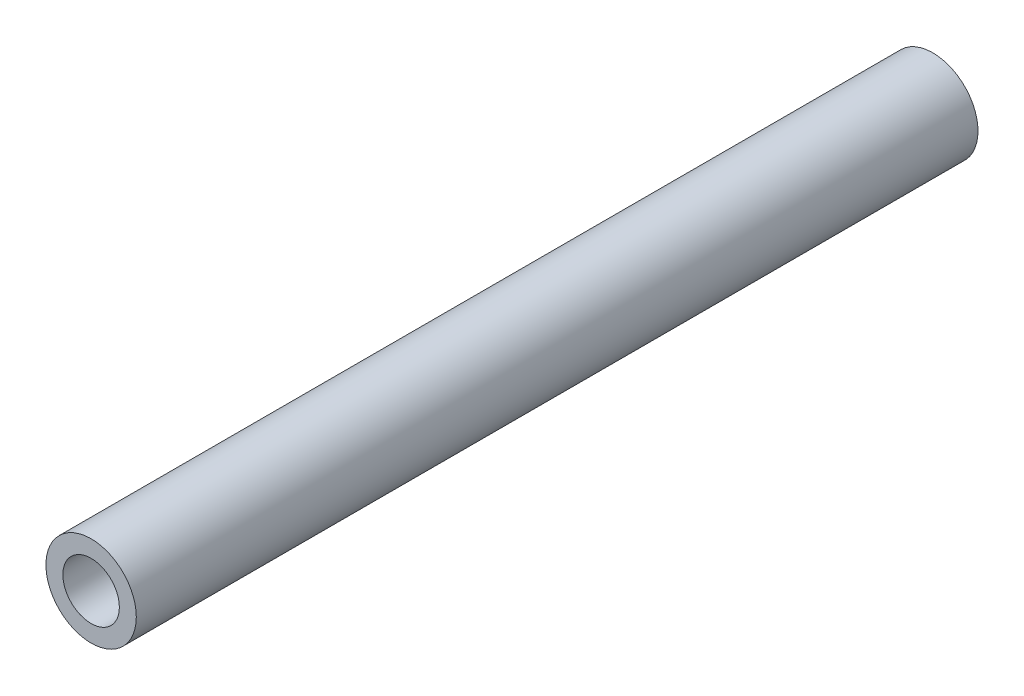
from build123d import *

# Parameters (mm, degrees)
SKETCH1_R           = 4
BOSS_EXTRUDE1_DEPTH = 74.5
SKETCH2_R           = 2.5
CUT_EXTRUDE1_DEPTH  = 16


with BuildPart() as part:
    # Sketch1 → Boss-Extrude1 (new body)
    with BuildSketch(Plane.XY):
        Circle(SKETCH1_R)
    extrude(amount=BOSS_EXTRUDE1_DEPTH)

    # Sketch2 → Cut-Extrude1 (cut)
    with BuildSketch(Plane.XY.offset(74.5)):
        Circle(SKETCH2_R)
    extrude(amount=-CUT_EXTRUDE1_DEPTH, mode=Mode.SUBTRACT)


solid = part.part
